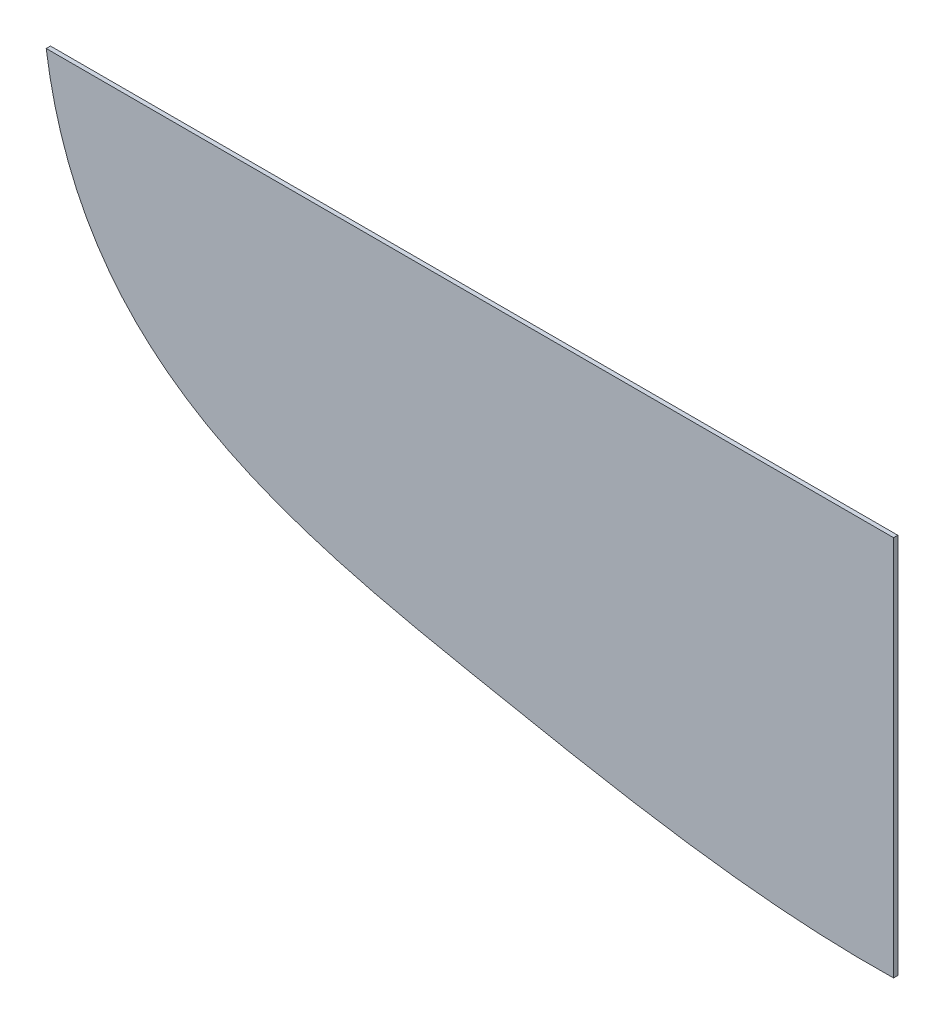
from build123d import *

# Parameters (mm, degrees)
EXTRUDE_1_DEPTH = 0.1


with BuildPart() as part:
    # 草图1 → 凸台-拉伸1 (new body, symmetric)
    with BuildSketch(Plane.XY):
        with BuildLine():
            Line((0, 0), (0, -18))
            add(Edge.make_bspline(
                [(-40, 0), (-38.330674915, -11.794377965), (-21.604049495, -15.210865673), (-6.577063135, -18.129665714), (0, -18)],
                knots=[0, 0, 0, 0, 0.585812167, 1, 1, 1, 1], degree=3))
            Line((-40, 0), (0, 0))
        make_face()
    extrude(amount=EXTRUDE_1_DEPTH, both=True)


solid = part.part
